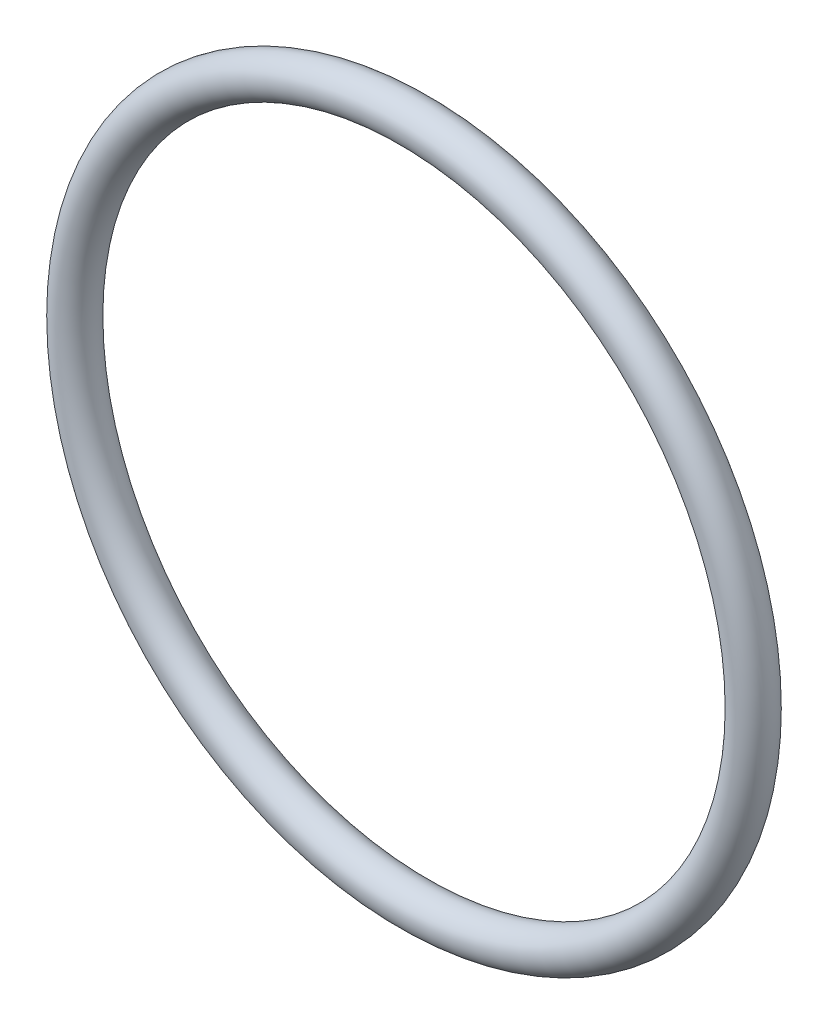
from build123d import *

# Parameters (mm, degrees)
SKETCH1_R = 1.7653


with BuildPart() as part:
    # Sketch1 → Revolve1 (revolve)
    with BuildSketch(Plane(origin=(0, 0, 0), x_dir=(0, -1, 0), z_dir=(1, 0, 0))):
        with Locations((30.1371, 0)):
            Circle(SKETCH1_R)
    revolve(axis=Axis((0, 0, 1.7653), (0, 0, -1)))


solid = part.part
